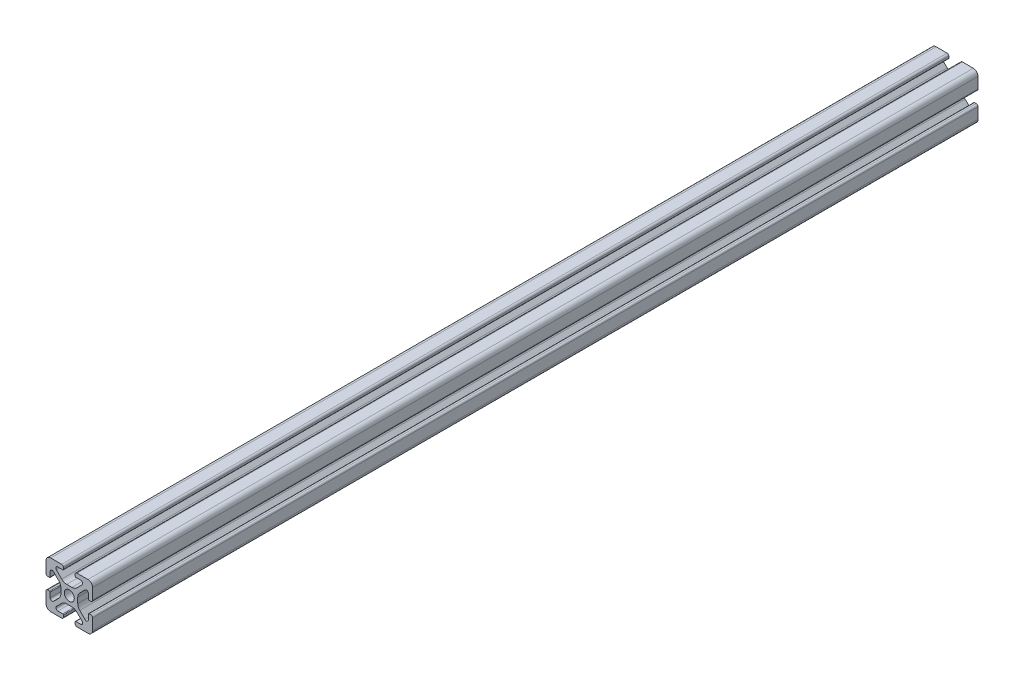
from build123d import *

# Parameters (mm, degrees)
SKETCH1_R           = 2.1463
BOSS_EXTRUDE1_DEPTH = 380.0204


with BuildPart() as part:
    # Sketch1 → Boss-Extrude1 (new body)
    with BuildSketch(Plane.XY):
        with BuildLine():
            Line((-9.9949, 7.9883), (-9.9949, 3.2893))
            ThreePointArc((-9.9949, 3.2893), (-9.76427588, 2.73252412), (-9.2075, 2.5019))
            Line((-9.2075, 2.5019), (-8.4963, 2.5019))
            ThreePointArc((-8.4963, 2.5019), (-8.280773853, 2.591173853), (-8.1915, 2.8067))
            Line((-8.1915, 2.8067), (-8.1915, 4.9149))
            ThreePointArc((-8.1915, 4.9149), (-7.674065253, 5.689295824), (-6.760603096, 5.507596904))
            Line((-6.760603096, 5.507596904), (-4.505765747, 3.252759555))
            ThreePointArc((-4.505765747, 3.252759555), (-3.856054457, 2.280397894), (-3.627906192, 1.133419111))
            Line((-3.627906192, 1.133419111), (-3.627906192, -1.133419111))
            ThreePointArc((-3.627906192, -1.133419111), (-3.856054457, -2.280397894), (-4.505765747, -3.252759555))
            Line((-4.505765747, -3.252759555), (-6.760603096, -5.507596904))
            ThreePointArc((-6.760603096, -5.507596904), (-7.674065253, -5.689295824), (-8.1915, -4.9149))
            Line((-8.1915, -4.9149), (-8.1915, -2.8067))
            ThreePointArc((-8.1915, -2.8067), (-8.280773853, -2.591173853), (-8.4963, -2.5019))
            Line((-8.4963, -2.5019), (-9.2075, -2.5019))
            ThreePointArc((-9.2075, -2.5019), (-9.76427588, -2.73252412), (-9.9949, -3.2893))
            Line((-9.9949, -3.2893), (-9.9949, -7.9883))
            ThreePointArc((-9.9949, -7.9883), (-9.407180467, -9.407180467), (-7.9883, -9.9949))
            Line((-7.9883, -9.9949), (-3.2893, -9.9949))
            ThreePointArc((-3.2893, -9.9949), (-2.73252412, -9.76427588), (-2.5019, -9.2075))
            Line((-2.5019, -9.2075), (-2.5019, -8.4963))
            ThreePointArc((-2.5019, -8.4963), (-2.591173853, -8.280773853), (-2.8067, -8.1915))
            Line((-2.8067, -8.1915), (-4.9149, -8.1915))
            ThreePointArc((-4.9149, -8.1915), (-5.689295824, -7.674065253), (-5.507596904, -6.760603096))
            Line((-5.507596904, -6.760603096), (-3.252759555, -4.505765747))
            ThreePointArc((-3.252759555, -4.505765747), (-2.280397894, -3.856054457), (-1.133419111, -3.627906192))
            Line((-1.133419111, -3.627906192), (1.133419111, -3.627906192))
            ThreePointArc((1.133419111, -3.627906192), (2.280397894, -3.856054457), (3.252759555, -4.505765747))
            Line((3.252759555, -4.505765747), (5.507596904, -6.760603096))
            ThreePointArc((5.507596904, -6.760603096), (5.689295824, -7.674065253), (4.9149, -8.1915))
            Line((4.9149, -8.1915), (2.8067, -8.1915))
            ThreePointArc((2.8067, -8.1915), (2.591173853, -8.280773853), (2.5019, -8.4963))
            Line((2.5019, -8.4963), (2.5019, -9.2075))
            ThreePointArc((2.5019, -9.2075), (2.73252412, -9.76427588), (3.2893, -9.9949))
            Line((3.2893, -9.9949), (7.9883, -9.9949))
            ThreePointArc((7.9883, -9.9949), (9.407180467, -9.407180467), (9.9949, -7.9883))
            Line((9.9949, -7.9883), (9.9949, -3.2893))
            ThreePointArc((9.9949, -3.2893), (9.76427588, -2.73252412), (9.2075, -2.5019))
            Line((9.2075, -2.5019), (8.4963, -2.5019))
            ThreePointArc((8.4963, -2.5019), (8.280773853, -2.591173853), (8.1915, -2.8067))
            Line((8.1915, -2.8067), (8.1915, -4.9149))
            ThreePointArc((8.1915, -4.9149), (7.674065253, -5.689295824), (6.760603096, -5.507596904))
            Line((6.760603096, -5.507596904), (4.505765747, -3.252759555))
            ThreePointArc((4.505765747, -3.252759555), (3.856054457, -2.280397894), (3.627906192, -1.133419111))
            Line((3.627906192, -1.133419111), (3.627906192, 1.133419111))
            ThreePointArc((3.627906192, 1.133419111), (3.856054457, 2.280397894), (4.505765747, 3.252759555))
            Line((4.505765747, 3.252759555), (6.760603096, 5.507596904))
            ThreePointArc((6.760603096, 5.507596904), (7.674065253, 5.689295824), (8.1915, 4.9149))
            Line((8.1915, 4.9149), (8.1915, 2.8067))
            ThreePointArc((8.1915, 2.8067), (8.280773853, 2.591173853), (8.4963, 2.5019))
            Line((8.4963, 2.5019), (9.2075, 2.5019))
            ThreePointArc((9.2075, 2.5019), (9.76427588, 2.73252412), (9.9949, 3.2893))
            Line((9.9949, 3.2893), (9.9949, 7.9883))
            ThreePointArc((9.9949, 7.9883), (9.407180467, 9.407180467), (7.9883, 9.9949))
            Line((7.9883, 9.9949), (3.2893, 9.9949))
            ThreePointArc((3.2893, 9.9949), (2.73252412, 9.76427588), (2.5019, 9.2075))
            Line((2.5019, 9.2075), (2.5019, 8.4963))
            ThreePointArc((2.5019, 8.4963), (2.591173853, 8.280773853), (2.8067, 8.1915))
            Line((2.8067, 8.1915), (4.9149, 8.1915))
            ThreePointArc((4.9149, 8.1915), (5.689295824, 7.674065253), (5.507596904, 6.760603096))
            Line((5.507596904, 6.760603096), (3.252759555, 4.505765747))
            ThreePointArc((3.252759555, 4.505765747), (2.280397894, 3.856054457), (1.133419111, 3.627906192))
            Line((1.133419111, 3.627906192), (-1.133419111, 3.627906192))
            ThreePointArc((-1.133419111, 3.627906192), (-2.280397894, 3.856054457), (-3.252759555, 4.505765747))
            Line((-3.252759555, 4.505765747), (-5.507596904, 6.760603096))
            ThreePointArc((-5.507596904, 6.760603096), (-5.689295824, 7.674065253), (-4.9149, 8.1915))
            Line((-4.9149, 8.1915), (-2.8067, 8.1915))
            ThreePointArc((-2.8067, 8.1915), (-2.591173853, 8.280773853), (-2.5019, 8.4963))
            Line((-2.5019, 8.4963), (-2.5019, 9.2075))
            ThreePointArc((-2.5019, 9.2075), (-2.73252412, 9.76427588), (-3.2893, 9.9949))
            Line((-3.2893, 9.9949), (-7.9883, 9.9949))
            ThreePointArc((-7.9883, 9.9949), (-9.407180467, 9.407180467), (-9.9949, 7.9883))
        make_face()
        Circle(SKETCH1_R, mode=Mode.SUBTRACT)
    extrude(amount=BOSS_EXTRUDE1_DEPTH)


solid = part.part
